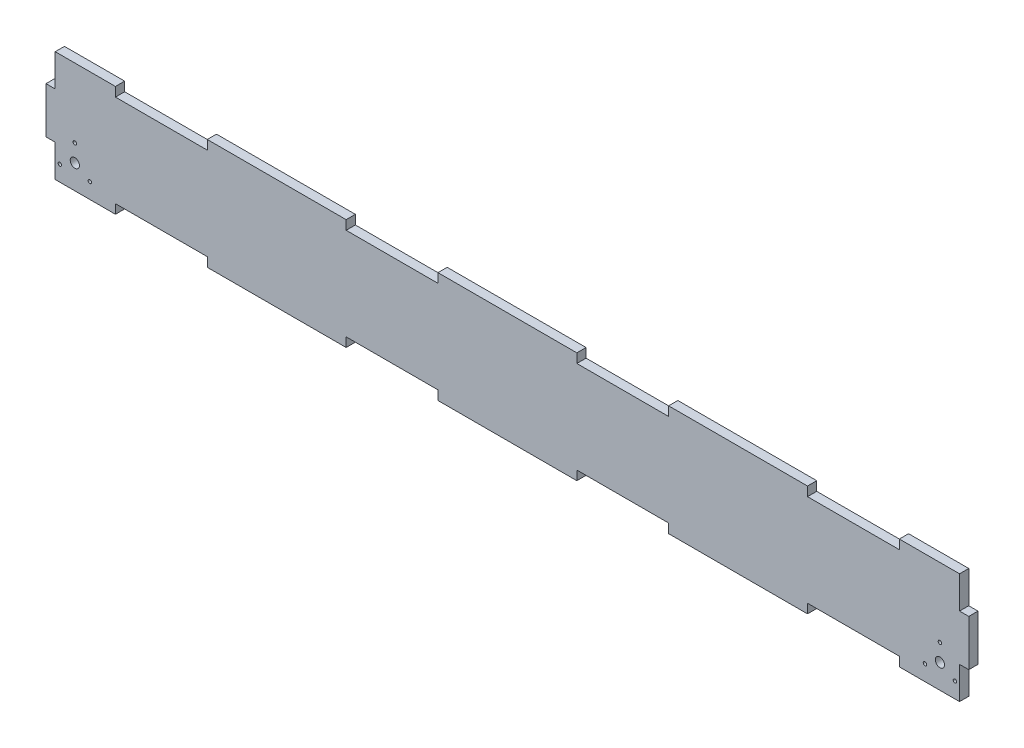
from build123d import *

# Parameters (mm, degrees)
BOSS_EXTRUDE1_DEPTH = 8
SKETCH2_R           = 4
SKETCH2_R_2         = 1.5
CUT_EXTRUDE1_DEPTH  = 10


with BuildPart() as part:
    # Sketch1 → Boss-Extrude1 (new body)
    with BuildSketch(Plane.XY):
        Polygon((392, -20), (392, -48), (339.8, -48), (339.8, -40), (260.2, -40), (260.2, -48), (139.8, -48), (139.8, -40), (60.2, -40), (60.2, -48), (-60.2, -48), (-60.2, -40), (-139.8, -40), (-139.8, -48), (-260.2, -48), (-260.2, -40), (-339.8, -40), (-339.8, -48), (-392, -48), (-392, -20), (-400, -20), (-400, 19.8), (-400, 20), (-392, 20), (-392, 48), (-339.8, 48), (-339.8, 40), (-260.2, 40), (-260.2, 48), (-139.8, 48), (-139.8, 40), (-60.2, 40), (-60.2, 48), (60.2, 48), (60.2, 40), (139.8, 40), (139.8, 48), (260.2, 48), (260.2, 40), (339.8, 40), (339.8, 48), (392, 48), (392, 20), (400, 20), (400, 19.8), (400, -20), align=None)
    extrude(amount=BOSS_EXTRUDE1_DEPTH)

    # Sketch2 → Cut-Extrude1 (cut)
    with BuildSketch(Plane.XY.offset(8)):
        with Locations((-375, -27)):
            Circle(SKETCH2_R)
        with Locations((375, -27)):
            Circle(SKETCH2_R)
        with Locations((-375, -12)):
            Circle(SKETCH2_R_2)
        with Locations((375, -12)):
            Circle(SKETCH2_R_2)
        with Locations((-362.009618943, -34.5)):
            Circle(SKETCH2_R_2)
        with Locations((-387.990381057, -34.5)):
            Circle(SKETCH2_R_2)
        with Locations((387.990381057, -34.5)):
            Circle(SKETCH2_R_2)
        with Locations((362.009618943, -34.5)):
            Circle(SKETCH2_R_2)
    extrude(amount=-CUT_EXTRUDE1_DEPTH, mode=Mode.SUBTRACT)


solid = part.part
